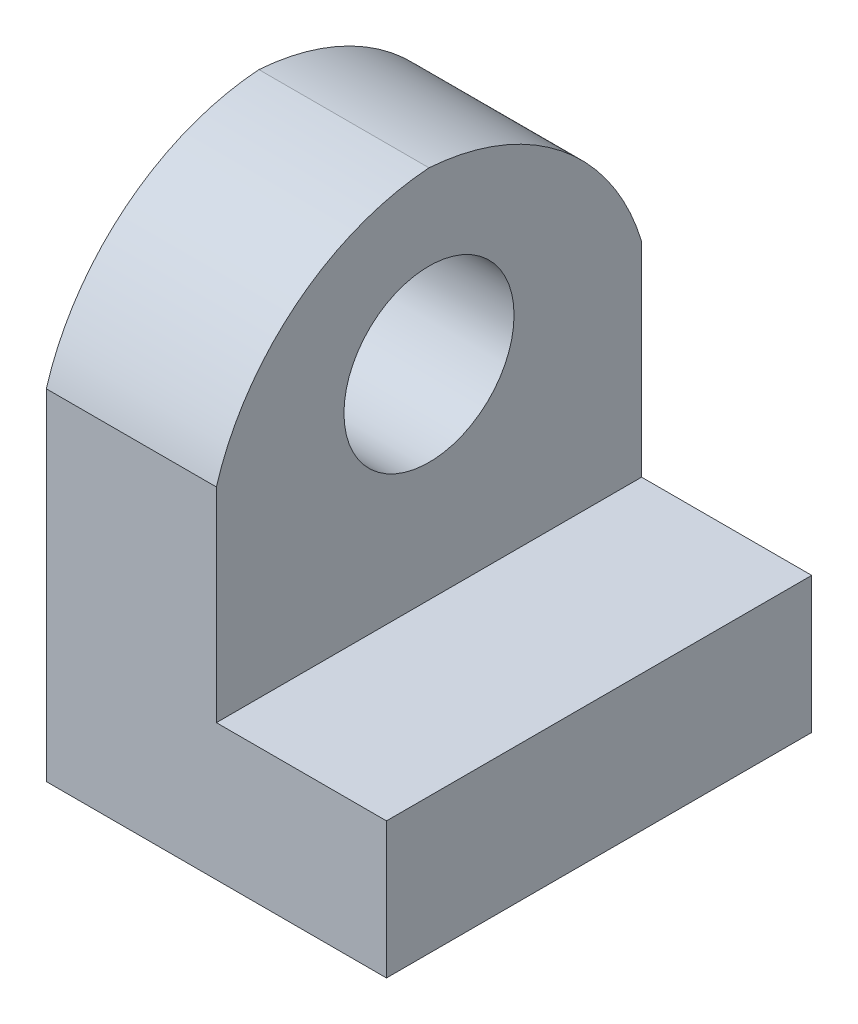
from build123d import *

# Parameters (mm, degrees)
CROQUIS1_W              = 20
CROQUIS1_H              = 25
SALIENTE_EXTRUIR1_DEPTH = 30
CROQUIS2_W              = 10
CROQUIS2_H              = 22
CORTAR_EXTRUIR1_DEPTH   = 30
CORTAR_EXTRUIR3_DEPTH   = 30
CROQUIS7_R              = 5
CORTAR_EXTRUIR4_DEPTH   = 30


with BuildPart() as part:
    # Croquis1 → Saliente-Extruir1 (new body)
    with BuildSketch(Plane(origin=(0, 0, 0), x_dir=(1, 0, 0), z_dir=(0, 1, 0))):
        with Locations((10, -12.5)):
            Rectangle(CROQUIS1_W, CROQUIS1_H)
    extrude(amount=SALIENTE_EXTRUIR1_DEPTH)

    # Croquis2 → Cortar-Extruir1 (cut)
    with BuildSketch(Plane.XY.offset(25)):
        with Locations((15, 19)):
            Rectangle(CROQUIS2_W, CROQUIS2_H)
    extrude(amount=-CORTAR_EXTRUIR1_DEPTH, mode=Mode.SUBTRACT)

    # Croquis6 → Cortar-Extruir3 (cut)
    with BuildSketch(Plane(origin=(10, 0, 0), x_dir=(0, 0, -1), z_dir=(1, 0, 0))):
        with BuildLine():
            Line((-25, 30), (-25, 20))
            ThreePointArc((-25, 20), (-20.308873363, 26.948591704), (-12.5, 30))
            Line((-12.5, 30), (-25, 30))
        make_face()
        with BuildLine():
            ThreePointArc((-12.5, 30), (-4.691126637, 26.948591704), (0, 20))
            Line((0, 20), (0, 30))
            Line((0, 30), (-12.5, 30))
        make_face()
    extrude(amount=-CORTAR_EXTRUIR3_DEPTH, mode=Mode.SUBTRACT)

    # Croquis7 → Cortar-Extruir4 (cut)
    with BuildSketch(Plane(origin=(10, 0, 0), x_dir=(0, 0, -1), z_dir=(1, 0, 0))):
        with Locations((-12.5, 20)):
            Circle(CROQUIS7_R)
    extrude(amount=-CORTAR_EXTRUIR4_DEPTH, mode=Mode.SUBTRACT)


solid = part.part
